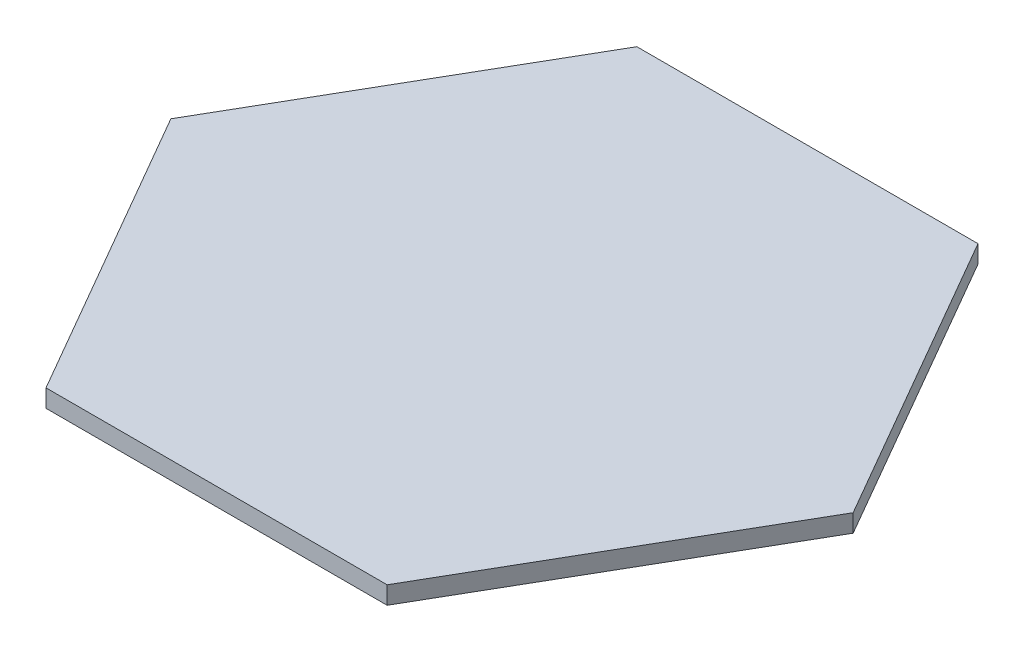
from build123d import *

# Parameters (mm, degrees)
BOSS_EXTRUDE1_DEPTH = 3.175


with BuildPart() as part:
    # Sketch1 → Boss-Extrude1 (new body)
    with BuildSketch(Plane(origin=(0, 0, 0), x_dir=(1, 0, 0), z_dir=(0, 1, 0))):
        Polygon((61.777945491, 1.35), (31.278684177, 54.176270189), (-29.719838451, 54.176270189), (-60.219099765, 1.35), (-29.719838451, -51.476270189), (31.278684177, -51.476270189), align=None)
    extrude(amount=BOSS_EXTRUDE1_DEPTH)


solid = part.part
